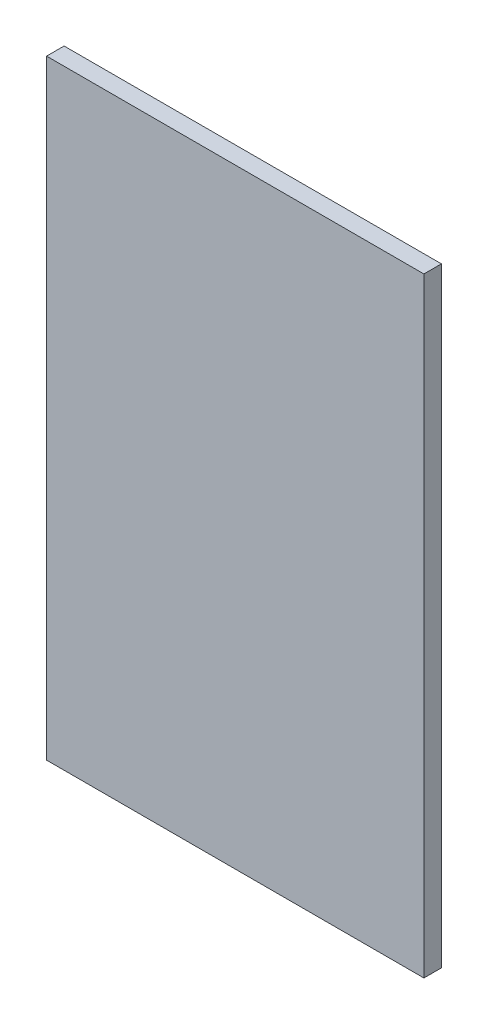
from build123d import *

# Parameters (mm, degrees)
SKETCH1_W           = 388
SKETCH1_H           = 627
BOSS_EXTRUDE1_DEPTH = 18


with BuildPart() as part:
    # Sketch1 → Boss-Extrude1 (new body)
    with BuildSketch(Plane.XY):
        Rectangle(SKETCH1_W, SKETCH1_H)
    extrude(amount=BOSS_EXTRUDE1_DEPTH)


solid = part.part
